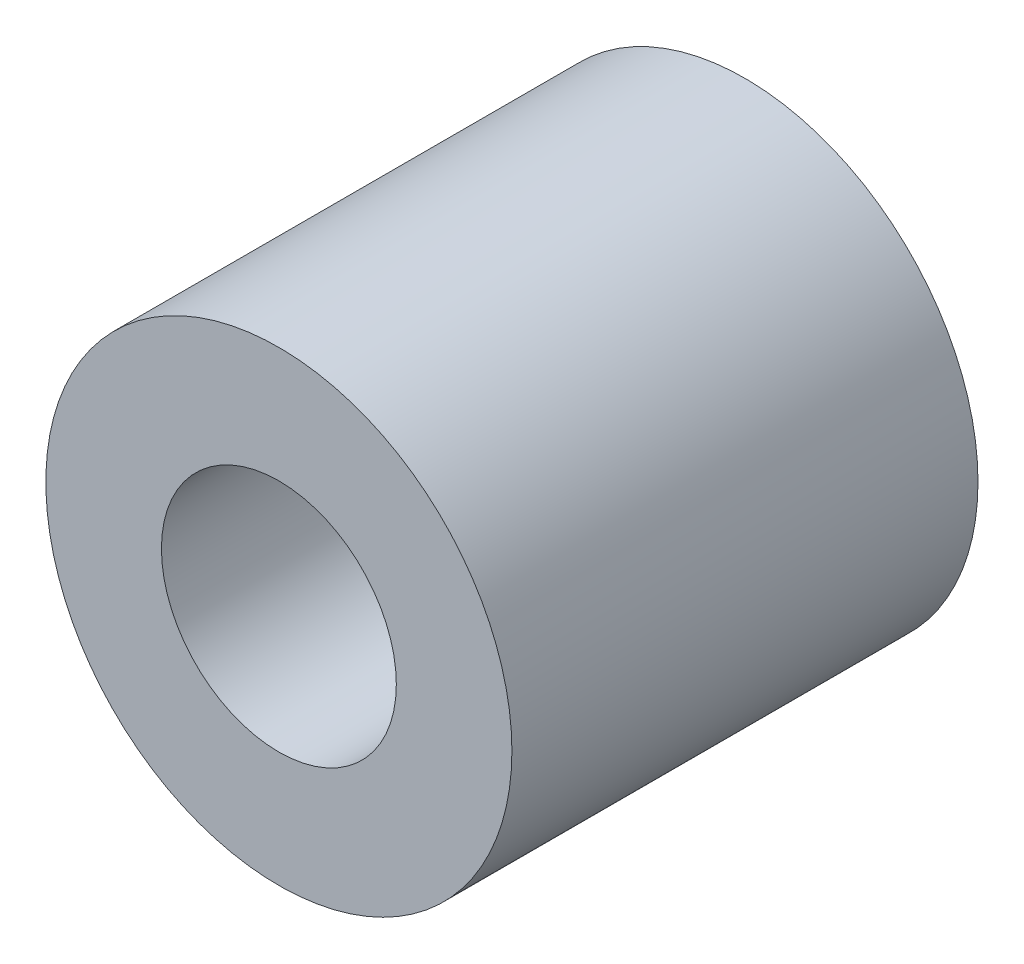
from build123d import *

# Parameters (mm, degrees)
SKETCH1_R           = 6.35
SKETCH1_R_2         = 3.2004
EXTRUDE1_DEPTH      = 6.35
EXTRUDE1_DEPTH_BACK = 6.35


with BuildPart() as part:
    # Sketch1 → Extrude1 (new body, two sides)
    with BuildSketch(Plane.XY) as extrude1_sk:
        Circle(SKETCH1_R)
        Circle(SKETCH1_R_2, mode=Mode.SUBTRACT)
    extrude(amount=EXTRUDE1_DEPTH)
    extrude(extrude1_sk.sketch, amount=-EXTRUDE1_DEPTH_BACK)


solid = part.part
